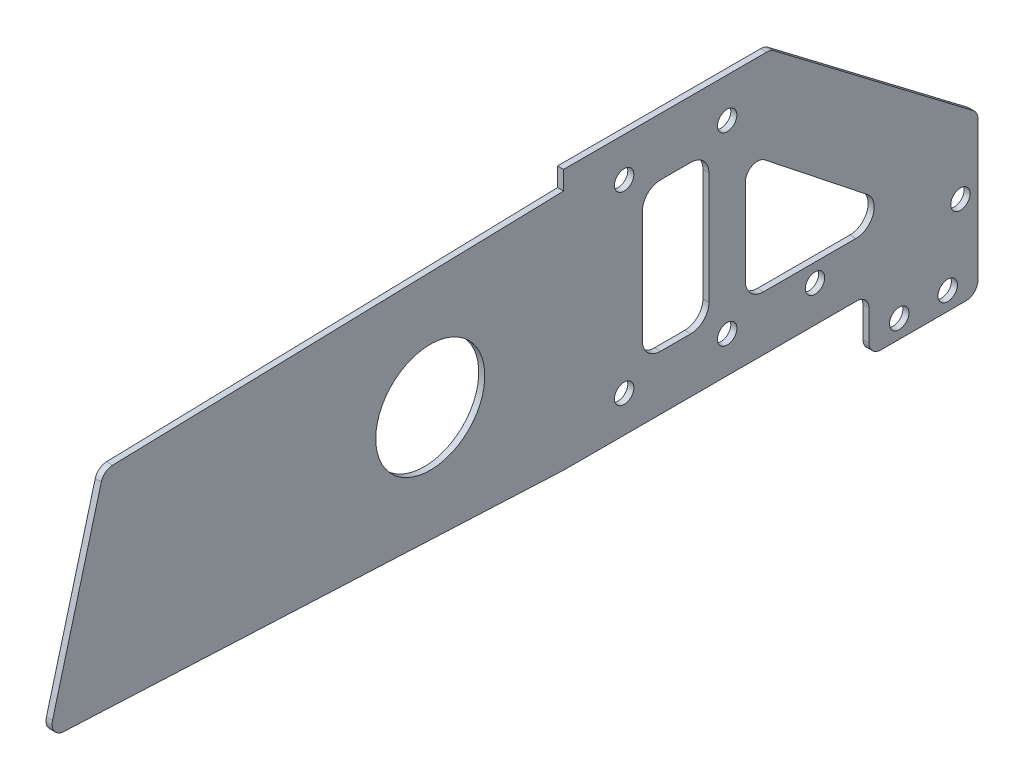
from build123d import *

# Parameters (mm, degrees)
SKETCH_1_W               = 58
SKETCH_1_H               = 44
SKETCH_1_R               = 1.6
EXTRUDE_1_DEPTH          = 1
SKETCH_2_W               = 132.5
SKETCH_2_H               = 90
EXTRUDE_2_DEPTH          = 1
SKETCH_6_W               = 15
SKETCH_6_H               = 90
CUT_EXTRUDE_4_DEPTH      = 1
CUT_EXTRUDE_4_DEPTH_BACK = 2
CUT_EXTRUDE_6_DEPTH      = 2
EXTRUDE_3_DEPTH          = 1
EXTRUDE_4_DEPTH          = 1
SKETCH_11_R              = 1.6
CUT_EXTRUDE_7_DEPTH      = 2
CUT_EXTRUDE_8_DEPTH      = 2
FILLET_3_R               = 2
SKETCH_14_R              = 1.6
CUT_EXTRUDE_9_DEPTH      = 2
SKETCH_15_R              = 9
CUT_EXTRUDE_10_DEPTH     = 2
CUT_EXTRUDE_11_DEPTH     = 2


with BuildPart() as part:
    # 草图1 → 凸台-拉伸1 (new body)
    with BuildSketch(Plane(origin=(0, 0, 0), x_dir=(0, 0, -1), z_dir=(1, 0, 0))):
        with Locations((19, -14.5)):
            Rectangle(SKETCH_1_W, SKETCH_1_H)
        Circle(SKETCH_1_R, mode=Mode.SUBTRACT)
        with Locations((17, 0)):
            Circle(SKETCH_1_R, mode=Mode.SUBTRACT)
        with Locations((0, -30.5)):
            Circle(SKETCH_1_R, mode=Mode.SUBTRACT)
        with Locations((17, -30.5)):
            Circle(SKETCH_1_R, mode=Mode.SUBTRACT)
        with Locations((31.5, -30.5)):
            Circle(SKETCH_1_R, mode=Mode.SUBTRACT)
    extrude(amount=EXTRUDE_1_DEPTH)

    # 草图2 → 凸台-拉伸2 (add)
    with BuildSketch(Plane(origin=(1, 0, 0), x_dir=(0, 0, -1), z_dir=(1, 0, 0))):
        with Locations((-18.25, 52.5)):
            Rectangle(SKETCH_2_W, SKETCH_2_H)
    extrude(amount=-EXTRUDE_2_DEPTH)

    # 草图6 → 切除-拉伸4 (cut, two sides)
    with BuildSketch(Plane(origin=(1, 0, 0), x_dir=(0, 0, -1), z_dir=(1, 0, 0))) as cut_extrude_4_sk:
        with Locations((40.5, 52.5)):
            Rectangle(SKETCH_6_W, SKETCH_6_H)
    extrude(amount=CUT_EXTRUDE_4_DEPTH, mode=Mode.SUBTRACT)
    extrude(cut_extrude_4_sk.sketch, amount=-CUT_EXTRUDE_4_DEPTH_BACK, mode=Mode.SUBTRACT)

    # 草图8 → 切除-拉伸6 (cut, through all)
    with BuildSketch(Plane(origin=(1, 0, 0), x_dir=(0, 0, -1), z_dir=(1, 0, 0))):
        Polygon((-84.5, 7.5), (-10, 7.5), (-10, 6.5), (48, 6.5), (48, 7.5), (33, 7.5), (33, 97.5), (-84.5, 97.5), align=None)
    extrude(amount=-CUT_EXTRUDE_6_DEPTH, mode=Mode.SUBTRACT)

    # 草图9 → 凸台-拉伸3 (add)
    with BuildSketch(Plane(origin=(1, 0, 0), x_dir=(0, 0, -1), z_dir=(1, 0, 0))):
        Polygon((-10, -32.5), (-10, 3.4), (-85.916522377, 1.4), (-95, -32.5), (-10, -36.5), align=None)
    extrude(amount=-EXTRUDE_3_DEPTH)

    # 草图10 → 凸台-拉伸4 (add)
    with BuildSketch(Plane(origin=(1, 0, 0), x_dir=(0, 0, -1), z_dir=(1, 0, 0))):
        Polygon((40.4, -45.5), (58.4, -45.5), (58.4, 6.5), (48, 6.5), (48, -36.5), (40.4, -36.5), align=None)
    extrude(amount=-EXTRUDE_4_DEPTH)

    # 草图11 → 切除-拉伸7 (cut, through all)
    with BuildSketch(Plane(origin=(1, 0, 0), x_dir=(0, 0, -1), z_dir=(1, 0, 0))):
        with Locations((45.4, -42.5)):
            Circle(SKETCH_11_R)
        with Locations((53.4, -42.5)):
            Circle(SKETCH_11_R)
    extrude(amount=-CUT_EXTRUDE_7_DEPTH, mode=Mode.SUBTRACT)

    # 草图13 → 切除-拉伸8 (cut, through all)
    with BuildSketch(Plane(origin=(1, 0, 0), x_dir=(0, 0, -1), z_dir=(1, 0, 0))):
        Polygon((24.2, 6.5), (58.4, -19.5), (58.4, 6.5), align=None)
    extrude(amount=-CUT_EXTRUDE_8_DEPTH, mode=Mode.SUBTRACT)

    # 圆角3
    fillet_3_edges = [part.edges().sort_by_distance(p)[0] for p in [
        (0.5, -32.5, 95),
        (0.5, 1.4, 85.916522377),
        (0.5, -45.5, -58.4),
        (0.5, -45.5, -40.4),
        (0.5, -36.5, -40.4),
        (0.5, 6.5, -24.2),
        (0.5, -19.5, -58.4),
    ]]
    fillet(fillet_3_edges, radius=FILLET_3_R)

    # 草图14 → 切除-拉伸9 (cut, through all)
    with BuildSketch(Plane(origin=(1, 0, 0), x_dir=(0, 0, -1), z_dir=(1, 0, 0))):
        with Locations((55.5, -30.5)):
            Circle(SKETCH_14_R)
    extrude(amount=-CUT_EXTRUDE_9_DEPTH, mode=Mode.SUBTRACT)

    # 草图15 → 切除-拉伸10 (cut, through all)
    with BuildSketch(Plane.ZY):
        with Locations((32, -16.5)):
            Circle(SKETCH_15_R)
    extrude(amount=-CUT_EXTRUDE_10_DEPTH, mode=Mode.SUBTRACT)

    # 草图16 → 切除-拉伸11 (cut, through all)
    with BuildSketch(Plane.ZY):
        with BuildLine():
            Line((-40.126719129, -22.148481915), (-23.2419273, -8.772218258))
            ThreePointArc((-23.2419273, -8.772218258), (-21.129326296, -8.5393617), (-20, -10.339896982))
            Line((-20, -10.339896982), (-20, -24.5))
            ThreePointArc((-20, -24.5), (-20.878679656, -26.621320344), (-23, -27.5))
            Line((-23, -27.5), (-31.5, -27.5))
            Line((-31.5, -27.5), (-38.263828178, -27.5))
            ThreePointArc((-38.263828178, -27.5), (-41.09707316, -25.48626714), (-40.126719129, -22.148481915))
        make_face()
        with BuildLine():
            Line((-14, -6), (-14, -24.5))
            ThreePointArc((-14, -24.5), (-13.121320344, -26.621320344), (-11, -27.5))
            Line((-11, -27.5), (-6, -27.5))
            ThreePointArc((-6, -27.5), (-3.878679656, -26.621320344), (-3, -24.5))
            Line((-3, -24.5), (-3, -6))
            ThreePointArc((-3, -6), (-3.878679656, -3.878679656), (-6, -3))
            Line((-6, -3), (-11, -3))
            ThreePointArc((-11, -3), (-13.121320344, -3.878679656), (-14, -6))
        make_face()
    extrude(amount=-CUT_EXTRUDE_11_DEPTH, mode=Mode.SUBTRACT)


solid = part.part
